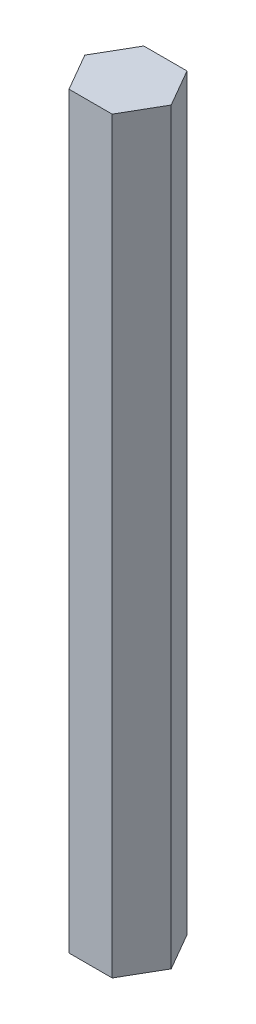
from build123d import *

# Parameters (mm, degrees)
BOSS_EXTRUDE1_DEPTH = 127


with BuildPart() as part:
    # Sketch1 → Boss-Extrude1 (new body)
    with BuildSketch(Plane(origin=(0, 0, 0), x_dir=(1, 0, 0), z_dir=(0, 1, 0))):
        Polygon((3.666174209, 6.35), (-3.666174209, 6.35), (-7.332348419, 0), (-3.666174209, -6.35), (3.666174209, -6.35), (7.332348419, 0), align=None)
    extrude(amount=BOSS_EXTRUDE1_DEPTH)


solid = part.part
